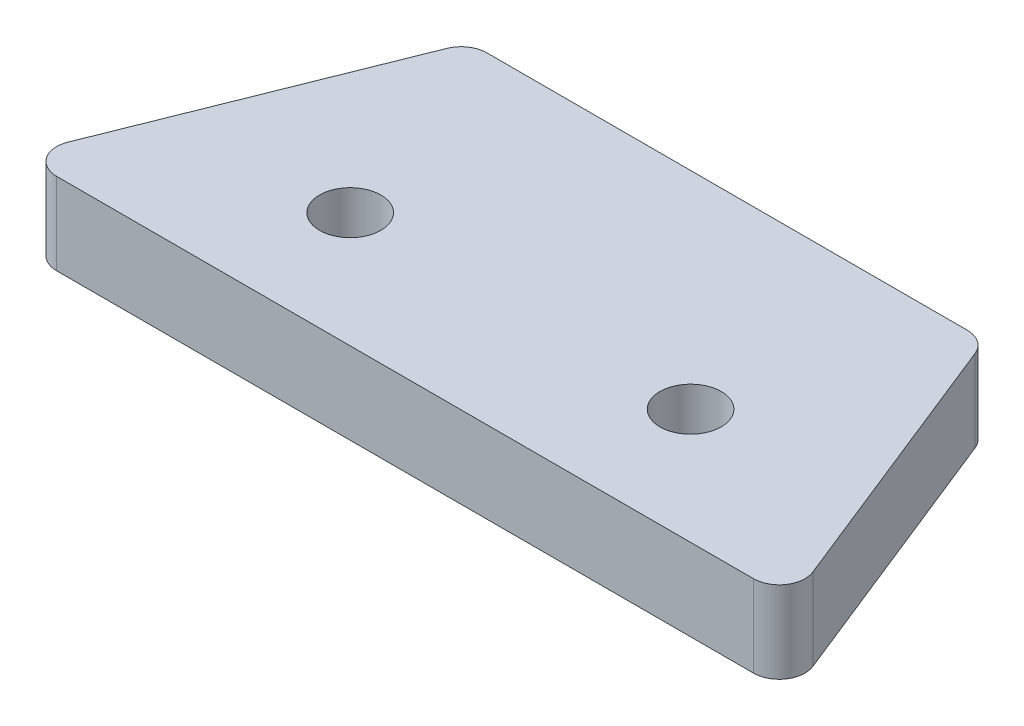
from build123d import *

# Parameters (mm, degrees)
SKETCH1_R           = 2.38
BOSS_EXTRUDE1_DEPTH = 6.35
FILLET1_R           = 2


with BuildPart() as part:
    # Sketch1 → Boss-Extrude1 (new body)
    with BuildSketch(Plane(origin=(0, 0, 0), x_dir=(1, 0, 0), z_dir=(0, 1, 0))):
        Polygon((-20, 12.5), (20, 12.5), (30, -12.5), (-30, -12.5), align=None)
        with Locations((-13.209810235, -3.549051176)):
            Circle(SKETCH1_R, mode=Mode.SUBTRACT)
        with Locations((13.209810235, -3.549051176)):
            Circle(SKETCH1_R, mode=Mode.SUBTRACT)
    extrude(amount=BOSS_EXTRUDE1_DEPTH)

    # Fillet1
    fillet1_edges = [part.edges().sort_by_distance(p)[0] for p in [
        (-20, 3.175, -12.5),
        (20, 3.175, -12.5),
        (30, 3.175, 12.5),
        (-30, 3.175, 12.5),
    ]]
    fillet(fillet1_edges, radius=FILLET1_R)


solid = part.part
